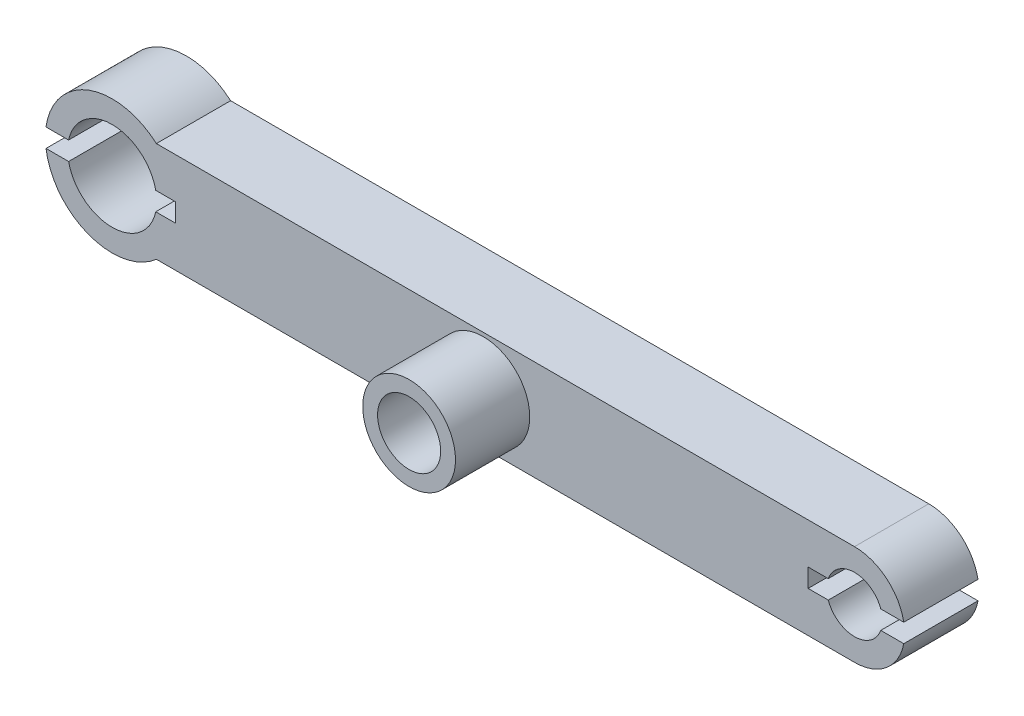
from build123d import *

# Parameters (mm, degrees)
ESQUISSE1_R                = 3.6
ESQUISSE1_R_2              = 2.4
CC_AXE_SERVO_DEPTH         = 3.9
ESQUISSE3_R                = 2.7
ESQUISSE3_R_2              = 1.5
CC_PIVOT_JAMBE_DEPTH       = 3.9
ESQUISSE4_R                = 2.4
ESQUISSE4_R_2              = 1.5
LIAISON_DEPTH              = 4
ESQUISSE9_W                = 7
ESQUISSE9_H                = 1
ELASTICITE_AXE_SERVO_DEPTH = 5
ESQUISSE7_R                = 1.7
PASSAGE_VIS_DEPTH          = 5
ESQUISSE8_R                = 2.5
ESQUISSE8_R_2              = 1.7
BUTEE_ASSEMBLAGE_DEPTH     = 4
ESQUISSE10_W               = 5.2
ESQUISSE10_H               = 1
ELASTICITE_DEPTH           = 9


with BuildPart() as part:
    # Esquisse1 → CC_AXE_SERVO (new body)
    with BuildSketch(Plane.XY):
        Circle(ESQUISSE1_R)
        Circle(ESQUISSE1_R_2, mode=Mode.SUBTRACT)
    extrude(amount=CC_AXE_SERVO_DEPTH)



with BuildPart() as body_2:
    # Esquisse3 → CC_PIVOT_JAMBE (new body)
    with BuildSketch(Plane.XY):
        with Locations((40, 0)):
            Circle(ESQUISSE3_R)
        with Locations((40, 0)):
            Circle(ESQUISSE3_R_2, mode=Mode.SUBTRACT)
    extrude(amount=CC_PIVOT_JAMBE_DEPTH)


with BuildPart() as part_1:
    add(part.part)

    add(body_2.part)  # LIAISON merges body 2
    # Esquisse4 → LIAISON (add)
    with BuildSketch(Plane.XY):
        with BuildLine():
            Line((2.38117618, 2.7), (40, 2.7))
            ThreePointArc((40, 2.7), (42.7, 0), (40, -2.7))
            Line((40, -2.7), (2.38117618, -2.7))
            ThreePointArc((2.38117618, -2.7), (-3.6, 0), (2.38117618, 2.7))
        make_face()
        Circle(ESQUISSE4_R, mode=Mode.SUBTRACT)
        with Locations((40, 0)):
            Circle(ESQUISSE4_R_2, mode=Mode.SUBTRACT)
    extrude(amount=LIAISON_DEPTH)

    # Esquisse9 → ELASTICITE_AXE_SERVO (cut, through all)
    with BuildSketch(Plane.XY):
        with Locations((-0.1, 0)):
            Rectangle(ESQUISSE9_W, ESQUISSE9_H)
    extrude(amount=ELASTICITE_AXE_SERVO_DEPTH, mode=Mode.SUBTRACT)

    # Esquisse7 → PASSAGE_VIS (cut, through all)
    with BuildSketch(Plane.XY):
        with Locations((20, 0)):
            Circle(ESQUISSE7_R)
    extrude(amount=PASSAGE_VIS_DEPTH, mode=Mode.SUBTRACT)

    # Esquisse8 → BUTEE_ASSEMBLAGE (add)
    with BuildSketch(Plane.XY.offset(4)):
        with Locations((20, 0)):
            Circle(ESQUISSE8_R)
        with Locations((20, 0)):
            Circle(ESQUISSE8_R_2, mode=Mode.SUBTRACT)
    extrude(amount=BUTEE_ASSEMBLAGE_DEPTH)

    # Esquisse10 → ELASTICITE (cut, through all)
    with BuildSketch(Plane.XY):
        with Locations((40.1, 0)):
            Rectangle(ESQUISSE10_W, ESQUISSE10_H)
    extrude(amount=ELASTICITE_DEPTH, mode=Mode.SUBTRACT)


solid = part_1.part
